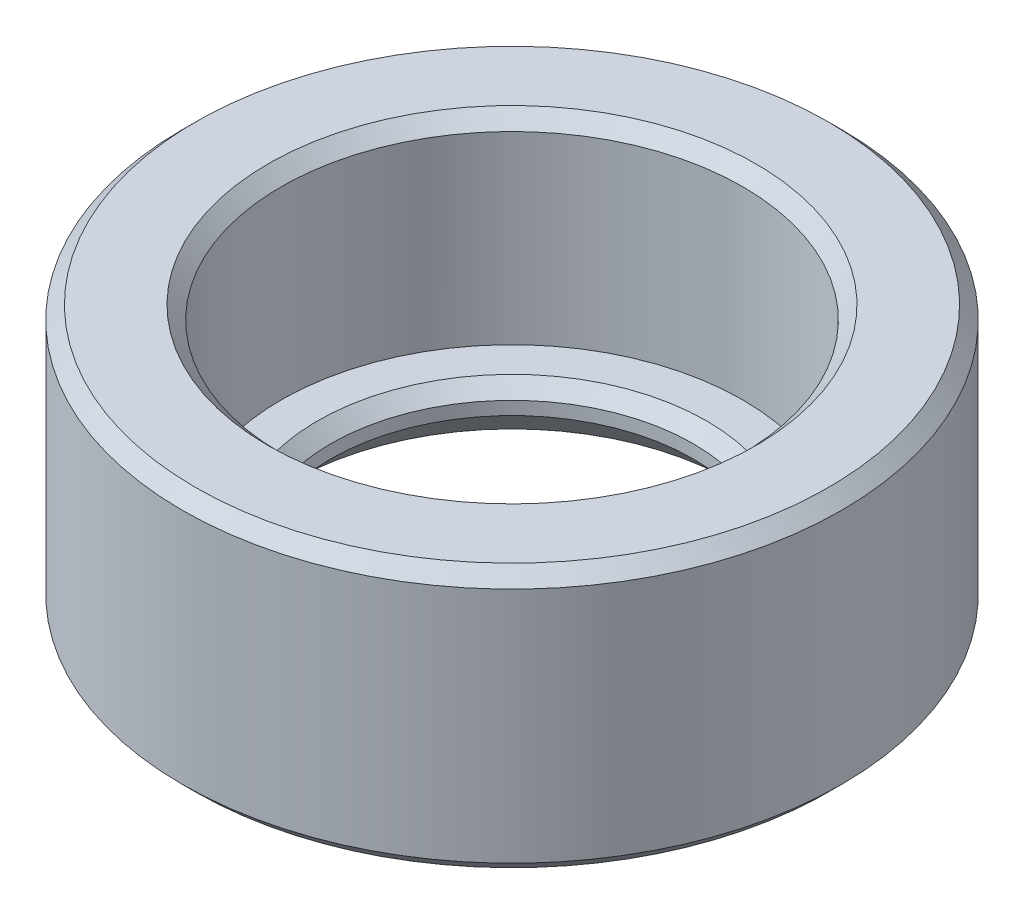
from build123d import *

# Parameters (mm, degrees)
SKETCH1_R           = 5
SKETCH1_R_2         = 3.5
BOSS_EXTRUDE1_DEPTH = 4
SKETCH2_R           = 5
SKETCH2_R_2         = 2.75
BOSS_EXTRUDE2_DEPTH = 1
CHAMFER1_SIZE       = 0.2
CHAMFER2_SIZE       = 0.6


with BuildPart() as part:
    # Sketch1 → Boss-Extrude1 (new body)
    with BuildSketch(Plane(origin=(0, 0, 0), x_dir=(1, 0, 0), z_dir=(0, 1, 0))):
        Circle(SKETCH1_R)
        Circle(SKETCH1_R_2, mode=Mode.SUBTRACT)
    extrude(amount=BOSS_EXTRUDE1_DEPTH)

    # Sketch2 → Boss-Extrude2 (add)
    with BuildSketch(Plane.XZ):
        Circle(SKETCH2_R)
        Circle(SKETCH2_R_2, mode=Mode.SUBTRACT)
    extrude(amount=-BOSS_EXTRUDE2_DEPTH)

    # Chamfer1
    chamfer1_edges = [part.edges().sort_by_distance(p)[0] for p in [
        (-2.75, 1, 0),
        (-5, 0, 0),
        (-5, 4, 0),
        (-3.5, 4, 0),
    ]]
    chamfer(chamfer1_edges, length=CHAMFER1_SIZE)

    # Chamfer2
    chamfer2_edges = [part.edges().sort_by_distance(p)[0] for p in [
        (-2.75, 0, 0),
    ]]
    chamfer(chamfer2_edges, length=CHAMFER2_SIZE)


solid = part.part
